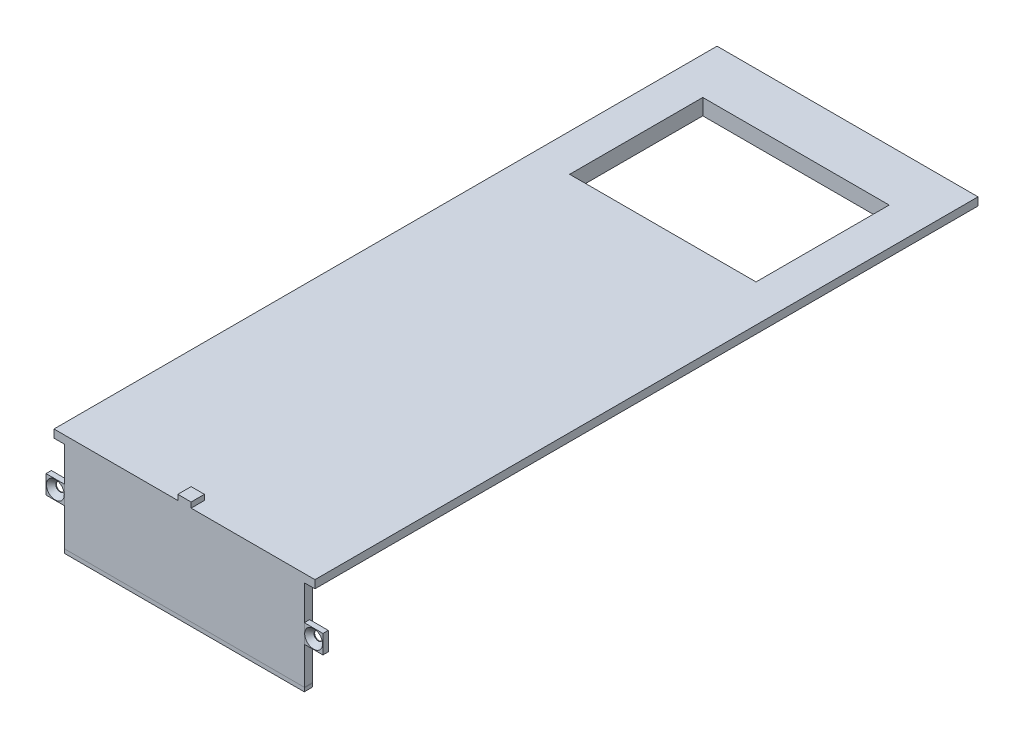
from build123d import *

# Parameters (mm, degrees)
BOSS_EXTRUDE1_DEPTH                          = 249
SKETCH4_W                                    = 90
SKETCH4_H                                    = 3
BOSS_EXTRUDE2_DEPTH                          = 31
SKETCH5_W                                    = 70
SKETCH5_H                                    = 50
CUT_EXTRUDE1_DEPTH                           = 7
SKETCH6_W                                    = 7
SKETCH6_H                                    = 7
SKETCH6_R                                    = 1.6
BOSS_EXTRUDE3_DEPTH                          = 2
BOSS_EXTRUDE3_2_DEPTH                        = 2
BOSS_EXTRUDE4_DEPTH                          = 3
SKETCH8_W                                    = 5
SKETCH8_H                                    = 5
BOSS_EXTRUDE5_DEPTH                          = 2
CUT_EXTRUDE2_DEPTH                           = 250
CSK_FOR_M3_HEX_SOCKET_COUNTERSUNK_CA_2_COUNT = 2
CSK_FOR_M3_HEX_SOCKET_COUNTERSUNK_CA_2_PITCH = 97


with BuildPart() as part:
    # Sketch2 → Boss-Extrude1 (new body)
    with BuildSketch(Plane.XY):
        Polygon((-50, 0), (50, 0), (50, -4), (45, -4), (45, -6), (-45, -6), (-45, -4), (-50, -4), align=None)
    extrude(amount=-BOSS_EXTRUDE1_DEPTH)

    # Sketch4 → Boss-Extrude2 (add)
    with BuildSketch(Plane.XZ.offset(6)):
        with Locations((0, -1.5)):
            Rectangle(SKETCH4_W, SKETCH4_H)
    extrude(amount=BOSS_EXTRUDE2_DEPTH)

    # Sketch5 → Cut-Extrude1 (cut)
    with BuildSketch(Plane(origin=(0, 0, 0), x_dir=(1, 0, 0), z_dir=(0, 1, 0))):
        with Locations((0, 204.645453138)):
            Rectangle(SKETCH5_W, SKETCH5_H)
    extrude(amount=-CUT_EXTRUDE1_DEPTH, mode=Mode.SUBTRACT)

    # Sketch8 → Boss-Extrude5 (add)
    with BuildSketch(Plane(origin=(0, 0, 0), x_dir=(1, 0, 0), z_dir=(0, 1, 0))):
        with Locations((0, 2.5)):
            Rectangle(SKETCH8_W, SKETCH8_H)
    extrude(amount=BOSS_EXTRUDE5_DEPTH)

    # Sketch9 → Cut-Extrude2 (cut, through all)
    with BuildSketch(Plane.XY):
        Polygon((-49, 0), (-49, -3), (-45, -3), (-45, -4), (-50, -4), (-50, 0), align=None)
        Polygon((49, 0), (50, 0), (50, -4), (45, -4), (45, -3), (49, -3), align=None)
    extrude(amount=-CUT_EXTRUDE2_DEPTH, mode=Mode.SUBTRACT)


with BuildPart() as body_2:
    # Sketch6 → Boss-Extrude3 (new body)
    with BuildSketch(Plane.XY):
        with Locations((-48.5, -19.5)):
            Rectangle(SKETCH6_W, SKETCH6_H)
        with Locations((-48.5, -19.5)):
            Circle(SKETCH6_R, mode=Mode.SUBTRACT)
    extrude(amount=-BOSS_EXTRUDE3_DEPTH)

    # Sketch13 → CSK for M3 Hex Socket Countersunk Cap Screw1 (revolve, cut)
    with BuildSketch(Plane(origin=(-48.5, -19.5, 0), x_dir=(0, -1, 0), z_dir=(1, 0, 0))):
        Polygon((0, 0), (0, 6.2), (1.6, 5.23862301), (1.6, 1.76), (3.36, 0), align=None)
    csk_for_m3_hex_socket_countersunk_cap_sc = revolve(axis=Axis((-48.5, -19.5, 6.35), (0, 0, -1)), mode=Mode.SUBTRACT)


with BuildPart() as body_3:
    # Sketch6 → Boss-Extrude3 2 (new body)
    with BuildSketch(Plane.XY):
        with Locations((48.5, -19.5)):
            Rectangle(SKETCH6_W, SKETCH6_H)
        with Locations((48.5, -19.5)):
            Circle(SKETCH6_R, mode=Mode.SUBTRACT)
    extrude(amount=-BOSS_EXTRUDE3_2_DEPTH)

    # CSK for M3 Hex Socket Countersunk Ca 2: CSK for M3 Hex Socket Countersunk Cap Screw1 ×2
    with Locations(*[(i * CSK_FOR_M3_HEX_SOCKET_COUNTERSUNK_CA_2_PITCH, 0, 0) for i in range(1, CSK_FOR_M3_HEX_SOCKET_COUNTERSUNK_CA_2_COUNT)]):
        add(csk_for_m3_hex_socket_countersunk_cap_sc, mode=Mode.SUBTRACT)


with BuildPart() as body_4:
    # Sketch7 → Boss-Extrude4 (new body)
    with BuildSketch(Plane.XY):
        Polygon((-45, -37), (-45, -38.500868281), (44.987948755, -38.500868281), (44.987948755, -37.250413364), (45, -37), align=None)
    extrude(amount=-BOSS_EXTRUDE4_DEPTH)


solid = Compound([part.part, body_2.part, body_3.part, body_4.part])
